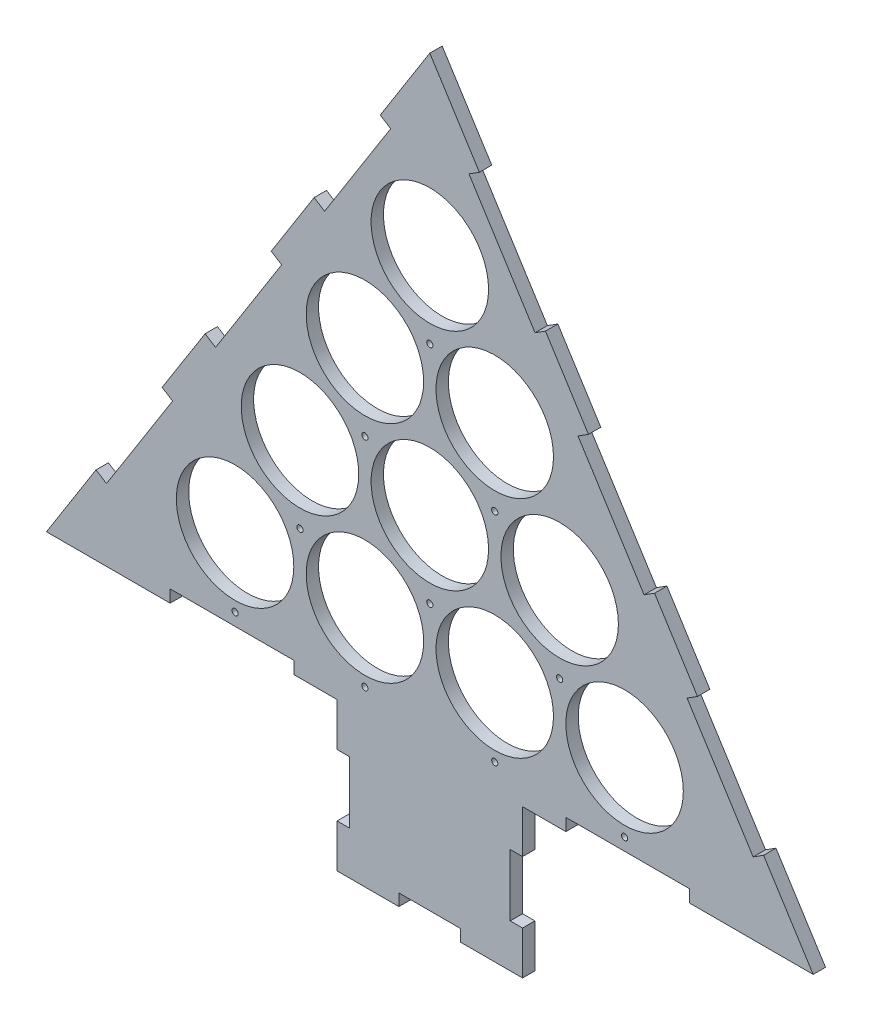
from build123d import *

# Parameters (mm, degrees)
ESQUISSE1_R             = 47.5
BOSS_EXTRU_1_DEPTH      = 10
ESQUISSE3_W             = 100
ESQUISSE3_H             = 10
ENL_V_MAT_EXTRU_1_DEPTH = 11
ESQUISSE4_R             = 2.5
ENL_V_MAT_EXTRU_2_DEPTH = 11
ESQUISSE6_W             = 150
ESQUISSE6_H             = 120
BOSS_EXTRU_2_DEPTH      = 10
ESQUISSE7_W             = 10
ESQUISSE7_H             = 50
ESQUISSE7_W_2           = 50
ESQUISSE7_H_2           = 9.570800355
ENL_V_MAT_EXTRU_3_DEPTH = 10


with BuildPart() as part:
    # Esquisse1 → Boss.-Extru.1 (new body)
    with BuildSketch(Plane.XY):
        Polygon((-310, -75.642859016), (0, 414.561180135), (310, -75.642859016), align=None)
        with Locations((-157.5, 0)):
            Circle(ESQUISSE1_R, mode=Mode.SUBTRACT)
        with Locations((-52.5, 0)):
            Circle(ESQUISSE1_R, mode=Mode.SUBTRACT)
        with Locations((52.5, 0)):
            Circle(ESQUISSE1_R, mode=Mode.SUBTRACT)
        with Locations((157.5, 0)):
            Circle(ESQUISSE1_R, mode=Mode.SUBTRACT)
        with Locations((-105, 90.932667397)):
            Circle(ESQUISSE1_R, mode=Mode.SUBTRACT)
        with Locations((0, 90.932667397)):
            Circle(ESQUISSE1_R, mode=Mode.SUBTRACT)
        with Locations((105, 90.932667397)):
            Circle(ESQUISSE1_R, mode=Mode.SUBTRACT)
        with Locations((-52.5, 181.865334795)):
            Circle(ESQUISSE1_R, mode=Mode.SUBTRACT)
        with Locations((52.5, 181.865334795)):
            Circle(ESQUISSE1_R, mode=Mode.SUBTRACT)
        with Locations((0, 272.798002192)):
            Circle(ESQUISSE1_R, mode=Mode.SUBTRACT)
    extrude(amount=BOSS_EXTRU_1_DEPTH)

    # Esquisse3 → Enlèv. mat.-Extru.1 (cut, through all)
    with BuildSketch(Plane.XY.offset(10)):
        Polygon((-269.913793103, -12.254405678), (-261.461999325, -17.599233264), (-208.013723463, 66.918704521), (-216.465517241, 72.263532107), align=None)
        Polygon((-181.724137931, 127.200191667), (-173.272344153, 121.855364081), (-119.82406829, 206.373301865), (-128.275862069, 211.718129452), align=None)
        Polygon((-93.534482759, 266.654789012), (-85.08268898, 261.309961425), (-31.634413118, 345.82789921), (-40.086206897, 351.172726796), align=None)
        Polygon((269.913793103, -12.254405678), (261.461999325, -17.599233264), (208.013723463, 66.918704521), (216.465517241, 72.263532107), align=None)
        Polygon((181.724137931, 127.200191667), (173.272344153, 121.855364081), (119.82406829, 206.373301865), (128.275862069, 211.718129452), align=None)
        Polygon((93.534482759, 266.654789012), (85.08268898, 261.309961425), (31.634413118, 345.82789921), (40.086206897, 351.172726796), align=None)
        with Locations((-160, -70.642859016)):
            Rectangle(ESQUISSE3_W, ESQUISSE3_H)
        with Locations((160, -70.642859016)):
            Rectangle(ESQUISSE3_W, ESQUISSE3_H)
    extrude(amount=-ENL_V_MAT_EXTRU_1_DEPTH, mode=Mode.SUBTRACT)

    # Esquisse4 → Enlèv. mat.-Extru.2 (cut, through all)
    with BuildSketch(Plane.XY.offset(10)):
        with Locations((-157.5, -55.642859016)):
            Circle(ESQUISSE4_R)
        with Locations((-52.5, -55.642859016)):
            Circle(ESQUISSE4_R)
        with Locations((52.5, -55.642859016)):
            Circle(ESQUISSE4_R)
        with Locations((157.5, -55.642859016)):
            Circle(ESQUISSE4_R)
        with Locations((-105, 29.047375097)):
            Circle(ESQUISSE4_R)
        with Locations((0, 29.047375097)):
            Circle(ESQUISSE4_R)
        with Locations((105, 29.047375097)):
            Circle(ESQUISSE4_R)
        with Locations((-52.5, 119.980042494)):
            Circle(ESQUISSE4_R)
        with Locations((52.5, 119.980042494)):
            Circle(ESQUISSE4_R)
        with Locations((0, 210.912709891)):
            Circle(ESQUISSE4_R)
    extrude(amount=-ENL_V_MAT_EXTRU_2_DEPTH, mode=Mode.SUBTRACT)

    # Esquisse6 → Boss.-Extru.2 (add)
    with BuildSketch(Plane.XY.offset(10)):
        with Locations((0, -135.642859016)):
            Rectangle(ESQUISSE6_W, ESQUISSE6_H)
    extrude(amount=-BOSS_EXTRU_2_DEPTH)

    # Esquisse7 → Enlèv. mat.-Extru.3 (cut)
    with BuildSketch(Plane.XY.offset(10)):
        with Locations((-70, -135.642859016)):
            Rectangle(ESQUISSE7_W, ESQUISSE7_H)
        with Locations((0, -190.857458839)):
            Rectangle(ESQUISSE7_W_2, ESQUISSE7_H_2)
        with Locations((70, -135.642859016)):
            Rectangle(ESQUISSE7_W, ESQUISSE7_H)
    extrude(amount=-ENL_V_MAT_EXTRU_3_DEPTH, mode=Mode.SUBTRACT)


solid = part.part
